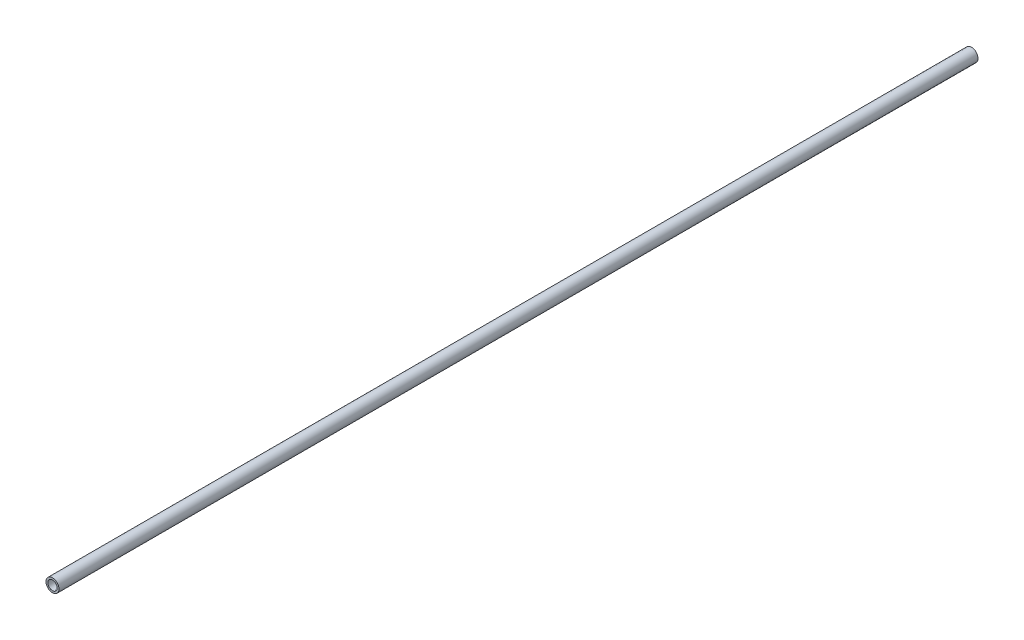
from build123d import *

# Parameters (mm, degrees)
SKETCH1_R           = 3.5
SKETCH1_R_2         = 2.5
BOSS_EXTRUDE1_DEPTH = 495


with BuildPart() as part:
    # Sketch1 → Boss-Extrude1 (new body)
    with BuildSketch(Plane.XY):
        with Locations((203.53267981, -1.775861049)):
            Circle(SKETCH1_R)
        with Locations((203.53267981, -1.775861049)):
            Circle(SKETCH1_R_2, mode=Mode.SUBTRACT)
    extrude(amount=-BOSS_EXTRUDE1_DEPTH)


solid = part.part
